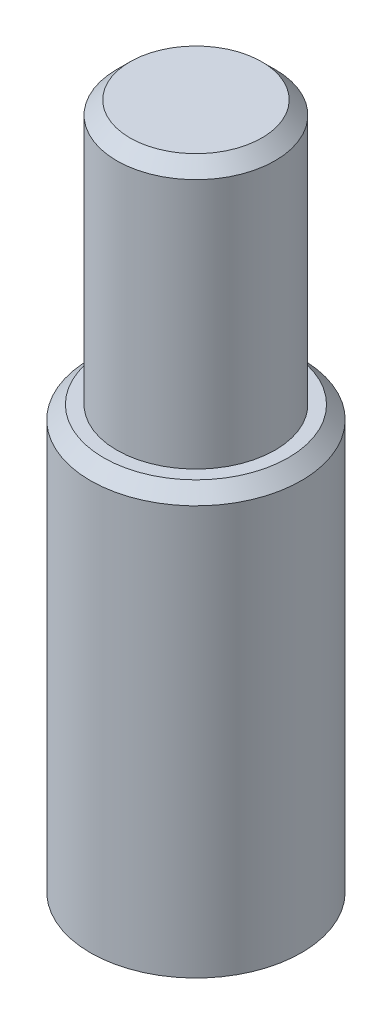
from build123d import *

# Parameters (mm, degrees)
M8_GEWINDEBOHRUNG1_D     = 6.8
M8_GEWINDEBOHRUNG1_DEPTH = 15
M8_GEWINDEBOHRUNG1_TIP   = 2.042926105
FASE1_SIZE               = 1
FASE2_SIZE               = 1


with BuildPart() as part:
    # Skizze1 → Rotation1 (revolve)
    with BuildSketch(Plane.XY):
        Polygon((0, 0), (-8, 0), (-8, 32), (-6, 32), (-6, 52), (0, 52), align=None)
    revolve(axis=Axis((0, 66.923871734, 0), (0, -1, 0)))

    # M8 Gewindebohrung1
    with Locations(Plane(origin=(0, 0, 0), x_dir=(-1, 0, 0), z_dir=(0, -1, 0))):
        with Locations((0, 0)):
            Hole(M8_GEWINDEBOHRUNG1_D / 2, depth=M8_GEWINDEBOHRUNG1_DEPTH)
            with Locations((0, 0, -(M8_GEWINDEBOHRUNG1_DEPTH + M8_GEWINDEBOHRUNG1_TIP / 2))):  # 118° drill point
                Cone(0, M8_GEWINDEBOHRUNG1_D / 2, M8_GEWINDEBOHRUNG1_TIP, mode=Mode.SUBTRACT)

    # Fase1
    fase1_edges = [part.edges().sort_by_distance(p)[0] for p in [
        (6, 52, 0),
    ]]
    chamfer(fase1_edges, length=FASE1_SIZE)

    # Fase2
    fase2_edges = [part.edges().sort_by_distance(p)[0] for p in [
        (8, 32, 0),
    ]]
    chamfer(fase2_edges, length=FASE2_SIZE)


solid = part.part
